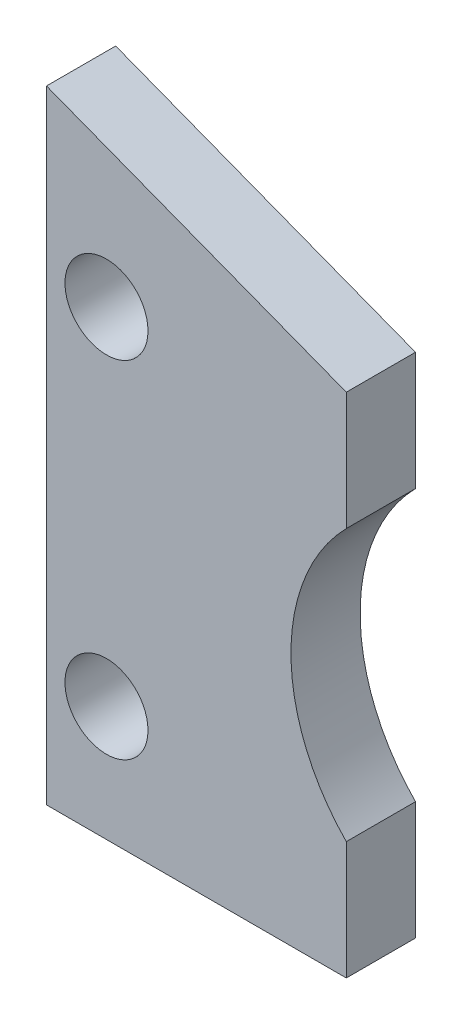
from build123d import *

# Parameters (mm, degrees)
Y_KSEKLIK_EKSTR_ZYON1_DEPTH = 7.5
IZIM2_R                     = 9
KES_EKSTR_ZYON1_DEPTH       = 16


with BuildPart() as part:
    # Çizim1 → Yükseklik-Ekstrüzyon1 (new body, symmetric)
    with BuildSketch(Plane.XY):
        with BuildLine():
            Line((0, 0), (0, 135))
            Line((0, 135), (65, 110))
            Line((65, 110), (65, 84.393876913))
            ThreePointArc((65, 84.393876913), (53, 55), (65, 25.606123087))
            Line((65, 25.606123087), (65, 0))
            Line((65, 0), (0, 0))
        make_face()
    extrude(amount=Y_KSEKLIK_EKSTR_ZYON1_DEPTH, both=True)

    # Çizim2 → Kes-Ekstrüzyon1 (cut, through all)
    with BuildSketch(Plane.XY.offset(7.5)):
        with Locations((13, 100)):
            Circle(IZIM2_R)
        with Locations((13, 25)):
            Circle(IZIM2_R)
    extrude(amount=-KES_EKSTR_ZYON1_DEPTH, mode=Mode.SUBTRACT)


solid = part.part
